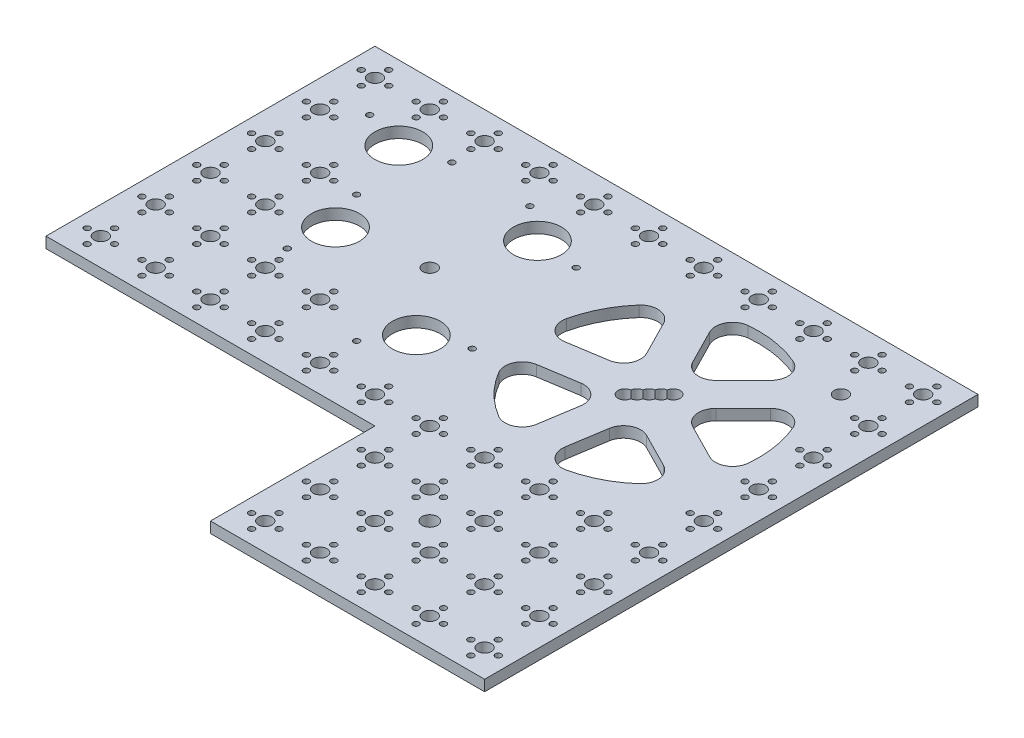
from build123d import *

# Parameters (mm, degrees)
BOSS_EXTRUDE1_DEPTH      = 6.35
SKETCH4_R                = 4
SKETCH4_R_2              = 14
SKETCH4_R_3              = 4.5
CUT_EXTRUDE1_DEPTH       = 341.223929934
SKETCH4_3_R              = 4
CUT_EXTRUDE6_DEPTH       = 341.223929934
LPATTERN3_COUNT          = 3
LPATTERN3_PITCH          = 5
LPATTERN3_COUNT_DIR2     = 3
LPATTERN3_PITCH_DIR2     = 5
SKETCH5_R                = 1.75
CUT_EXTRUDE2_DEPTH       = 341.223929934
CUT_EXTRUDE3_DEPTH       = 341.223929934
FILLET2_R                = 10
CIRPATTERN2_COUNT        = 5
FILLET2_OF_CIRPATTERN2_R = 10
SKETCH7_R                = 4
CUT_EXTRUDE4_DEPTH       = 341.223929934
SKETCH10_R               = 1.75
CUT_EXTRUDE5_DEPTH       = 341.223929934
LPATTERN1_COUNT          = 11
LPATTERN1_PITCH          = 32
LPATTERN1_COUNT_DIR2     = 9
LPATTERN1_PITCH_DIR2     = 32
LPATTERN2_COUNT          = 11
LPATTERN2_PITCH          = 32
LPATTERN2_COUNT_DIR2     = 9
LPATTERN2_PITCH_DIR2     = 32
SKETCH12_R               = 4
CUT_EXTRUDE8_DEPTH       = 341.223929934


with BuildPart() as part:
    # Sketch3 → Boss-Extrude1 (new body)
    with BuildSketch(Plane(origin=(0, 0, 0), x_dir=(1, 0, 0), z_dir=(0, 1, 0))):
        Polygon((-256, 224), (-256, 32), (-64, 32), (-64, -64), (96, -64), (96, 224), align=None)
    extrude(amount=BOSS_EXTRUDE1_DEPTH)

    # Sketch4 → Cut-Extrude1 (cut, through all)
    with BuildSketch(Plane(origin=(0, 6.35, 0), x_dir=(1, 0, 0), z_dir=(0, 1, 0))):
        with Locations((-128, 128)):
            Circle(SKETCH4_R)
        with Locations((-198.781646122, 180.692551193)):
            Circle(SKETCH4_R_2)
        with Locations((-110.195731373, 173.047286474)):
            Circle(SKETCH4_R_2)
        with Locations((-97.890039855, 90.057407837)):
            Circle(SKETCH4_R_2)
        with Locations((-175.914228771, 120.895305689)):
            Circle(SKETCH4_R_2)
        Circle(SKETCH4_R_3)
    extrude(amount=-CUT_EXTRUDE1_DEPTH, mode=Mode.SUBTRACT)

    # Sketch4_3 → Cut-Extrude6 (cut, through all)
    with BuildSketch(Plane(origin=(0, 6.35, 0), x_dir=(1, 0, 0), z_dir=(0, 1, 0))):
        with Locations((0, 128)):
            Circle(SKETCH4_3_R)
    cut_extrude6 = extrude(amount=-CUT_EXTRUDE6_DEPTH, mode=Mode.SUBTRACT)

    # LPattern3: Cut-Extrude6 3 × 3
    with Locations(*[Vector(0.7071067811865465, 0, -0.7071067811865486) * (i * LPATTERN3_PITCH) + Vector(-0.7071067811865465, 0, 0.7071067811865486) * (j * LPATTERN3_PITCH_DIR2) for i in range(LPATTERN3_COUNT) for j in range(LPATTERN3_COUNT_DIR2) if (i, j) != (0, 0)]):
        add(cut_extrude6, mode=Mode.SUBTRACT)

    # Sketch5 → Cut-Extrude2 (cut, through all)
    with BuildSketch(Plane(origin=(0, 6.35, 0), x_dir=(1, 0, 0), z_dir=(0, 1, 0))):
        with Locations((-222.781646122, 187.692551193)):
            Circle(SKETCH5_R)
        with Locations((-174.781646122, 187.692551193)):
            Circle(SKETCH5_R)
        with Locations((-129.942684691, 188.378882433)):
            Circle(SKETCH5_R)
        with Locations((-85.302834348, 170.735646865)):
            Circle(SKETCH5_R)
        with Locations((-74.739011615, 99.492973078)):
            Circle(SKETCH5_R)
        with Locations((-112.338426994, 69.655346443)):
            Circle(SKETCH5_R)
        with Locations((-179.318303693, 96.128144489)):
            Circle(SKETCH5_R)
        with Locations((-186.358738658, 143.609006692)):
            Circle(SKETCH5_R)
    extrude(amount=-CUT_EXTRUDE2_DEPTH, mode=Mode.SUBTRACT)

    # Sketch6 → Cut-Extrude3 (cut, through all)
    with BuildSketch(Plane(origin=(0, 6.35, 0), x_dir=(1, 0, 0), z_dir=(0, 1, 0))):
        with BuildLine():
            Line((-19.788455032, 188.86392238), (2.661422083, 144.803557707))
            Line((2.661422083, 144.803557707), (37.627925465, 179.770061089))
            ThreePointArc((37.627925465, 179.770061089), (10.011805763, 191.212053798), (-19.788455032, 188.86392238))
        make_face()
    cut_extrude3 = extrude(amount=-CUT_EXTRUDE3_DEPTH, mode=Mode.SUBTRACT)

    # Fillet2
    fillet2_edges = [part.edges().sort_by_distance(p)[0] for p in [
        (2.661422083, 3.175, -144.803557707),
        (-19.788455032, 3.175, -188.86392238),
        (37.627925465, 3.175, -179.770061089),
    ]]
    fillet(fillet2_edges, radius=FILLET2_R)

    # CirPattern2: Cut-Extrude3 ×5 about axis
    cirpattern2_axis = Axis((0, 0, -128), (0, 1, 0))
    for i in range(1, CIRPATTERN2_COUNT):
        add(cut_extrude3.rotate(cirpattern2_axis, i * 360 / CIRPATTERN2_COUNT), mode=Mode.SUBTRACT)

    # Fillet2 of CirPattern2
    fillet2_of_cirpattern2_edges = [part.edges().sort_by_distance(p)[0] for p in [
        (-15.158708401, 3.175, -135.723747712),
        (-63.999998884, 3.175, -127.988047254),
        (-37.608585516, 3.175, -179.784112385),
        (-12.0300191, 3.175, -115.9699809),
        (-19.765719558, 3.175, -67.128690417),
        (-60.871309583, 3.175, -108.234280442),
        (7.723747712, 3.175, -112.841291599),
        (51.784112385, 3.175, -90.391414484),
        (-0.011952746, 3.175, -64.000001116),
        (16.803557707, 3.175, -130.661422083),
        (51.770061089, 3.175, -165.627925465),
        (60.86392238, 3.175, -108.211544968),
    ]]
    fillet(fillet2_of_cirpattern2_edges, radius=FILLET2_OF_CIRPATTERN2_R)

    # Sketch7 → Cut-Extrude4 (cut, through all)
    with BuildSketch(Plane(origin=(0, 6.35, 0), x_dir=(1, 0, 0), z_dir=(0, 1, 0))):
        with Locations((80, 208)):
            Circle(SKETCH7_R)
    cut_extrude4 = extrude(amount=-CUT_EXTRUDE4_DEPTH, mode=Mode.SUBTRACT)

    # Sketch10 → Cut-Extrude5 (cut, through all)
    with BuildSketch(Plane(origin=(0, 6.35, 0), x_dir=(1, 0, 0), z_dir=(0, 1, 0))):
        with Locations((88, 208)):
            Circle(SKETCH10_R)
        with Locations((80, 200)):
            Circle(SKETCH10_R)
        with Locations((72, 208)):
            Circle(SKETCH10_R)
        with Locations((80, 216)):
            Circle(SKETCH10_R)
    cut_extrude5 = extrude(amount=-CUT_EXTRUDE5_DEPTH, mode=Mode.SUBTRACT)

    # LPattern1: Cut-Extrude4 11 × 9, 31 skipped
    with Locations(*[(-i * LPATTERN1_PITCH, 0, j * LPATTERN1_PITCH_DIR2) for i in range(LPATTERN1_COUNT) for j in range(LPATTERN1_COUNT_DIR2) if (i, j) not in ((0, 0), (1, 1), (1, 2), (1, 3), (1, 4), (2, 1), (2, 2), (2, 3), (2, 4), (3, 1), (3, 2), (3, 3), (3, 4), (4, 1), (4, 2), (4, 3), (4, 4), (5, 1), (5, 2), (5, 3), (5, 4), (6, 1), (6, 2), (6, 3), (6, 4), (7, 1), (7, 2), (7, 3), (8, 1), (8, 2), (8, 3), (9, 1))]):
        add(cut_extrude4, mode=Mode.SUBTRACT)

    # LPattern2: Cut-Extrude5 11 × 9, 31 skipped
    with Locations(*[(-i * LPATTERN2_PITCH, 0, j * LPATTERN2_PITCH_DIR2) for i in range(LPATTERN2_COUNT) for j in range(LPATTERN2_COUNT_DIR2) if (i, j) not in ((0, 0), (1, 1), (1, 2), (1, 3), (1, 4), (2, 1), (2, 2), (2, 3), (2, 4), (3, 1), (3, 2), (3, 3), (3, 4), (4, 1), (4, 2), (4, 3), (4, 4), (5, 1), (5, 2), (5, 3), (5, 4), (6, 1), (6, 2), (6, 3), (6, 4), (7, 1), (7, 2), (7, 3), (8, 1), (8, 2), (8, 3), (9, 1))]):
        add(cut_extrude5, mode=Mode.SUBTRACT)

    # Sketch12 → Cut-Extrude8 (cut, through all)
    with BuildSketch(Plane(origin=(0, 6.35, 0), x_dir=(1, 0, 0), z_dir=(0, 1, 0))):
        with Locations((56, 184)):
            Circle(SKETCH12_R)
    extrude(amount=-CUT_EXTRUDE8_DEPTH, mode=Mode.SUBTRACT)


solid = part.part
